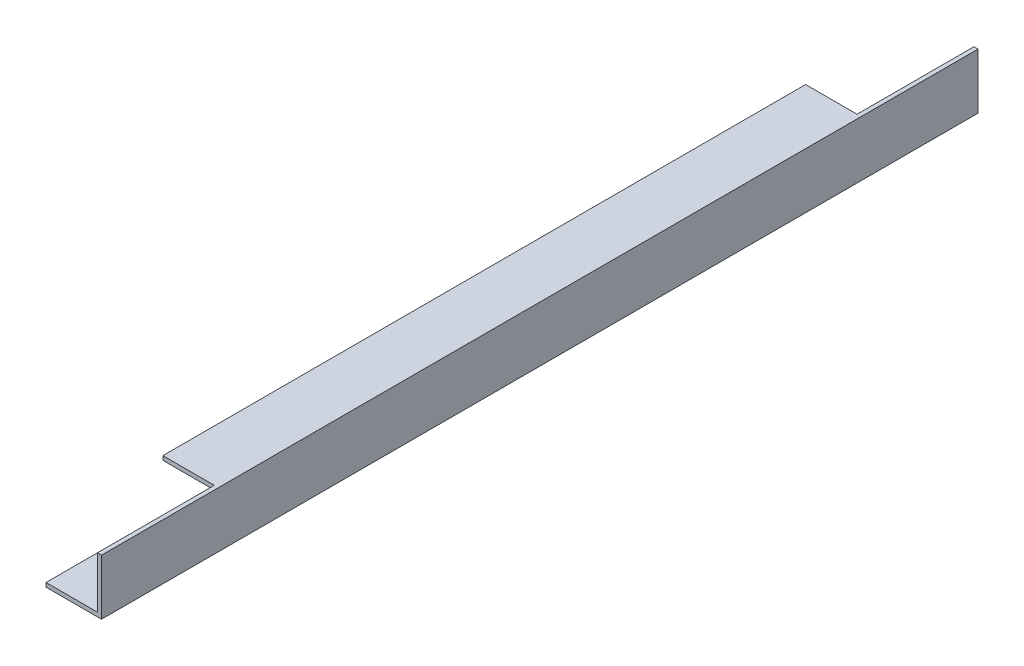
from build123d import *

# Parameters (mm, degrees)
BOSS_EXTRUDE1_DEPTH = 75
SKETCH2_W           = 8.8
SKETCH2_H           = 20
CUT_EXTRUDE1_DEPTH  = 0.7


with BuildPart() as part:
    # Sketch1 → Boss-Extrude1 (new body, symmetric)
    with BuildSketch(Plane.XY):
        Polygon((4.75, 4.75), (4.75, -4.75), (-4.75, -4.75), (-4.75, -4.05), (4.05, -4.05), (4.05, 4.05), (-4.75, 4.05), (-4.75, 4.75), align=None)
    extrude(amount=BOSS_EXTRUDE1_DEPTH, both=True)

    # Sketch2 → Cut-Extrude1 (cut)
    with BuildSketch(Plane(origin=(0, 4.75, 0), x_dir=(1, 0, 0), z_dir=(0, 1, 0))):
        with Locations((-0.35, 65)):
            Rectangle(SKETCH2_W, SKETCH2_H)
    cut_extrude1 = extrude(amount=-CUT_EXTRUDE1_DEPTH, mode=Mode.SUBTRACT)

    # Mirror1: Cut-Extrude1 across plane
    add(cut_extrude1.mirror(Plane.XY), mode=Mode.SUBTRACT)


solid = part.part
